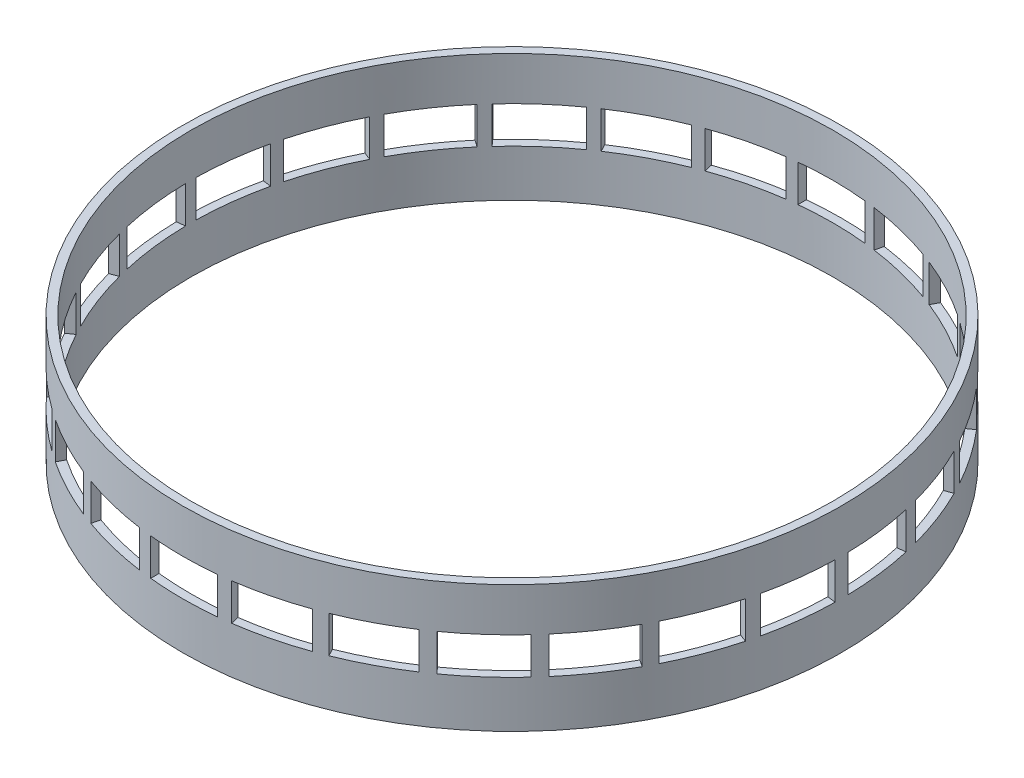
from build123d import *

# Parameters (mm, degrees)
SKETCH1_R           = 98.5
SKETCH1_R_2         = 96
BOSS_EXTRUDE1_DEPTH = 38
SKETCH2_W           = 20
SKETCH2_H           = 11
CUT_EXTRUDE1_DEPTH  = 99.5
CIRPATTERN1_COUNT   = 13


with BuildPart() as part:
    # Sketch1 → Boss-Extrude1 (new body)
    with BuildSketch(Plane(origin=(0, 0, 0), x_dir=(1, 0, 0), z_dir=(0, 1, 0))):
        Circle(SKETCH1_R)
        Circle(SKETCH1_R_2, mode=Mode.SUBTRACT)
    extrude(amount=BOSS_EXTRUDE1_DEPTH)

    # Sketch2 → Cut-Extrude1 (cut, symmetric)
    with BuildSketch(Plane.XY):
        with Locations((0, 19.5)):
            Rectangle(SKETCH2_W, SKETCH2_H)
    cut_extrude1 = extrude(amount=CUT_EXTRUDE1_DEPTH, both=True, mode=Mode.SUBTRACT)

    # CirPattern1: Cut-Extrude1 ×13 about axis
    cirpattern1_axis = Axis((0, 0, 0), (0, 1, 0))
    for i in range(1, CIRPATTERN1_COUNT):
        add(cut_extrude1.rotate(cirpattern1_axis, i * 360 / CIRPATTERN1_COUNT), mode=Mode.SUBTRACT)


solid = part.part
